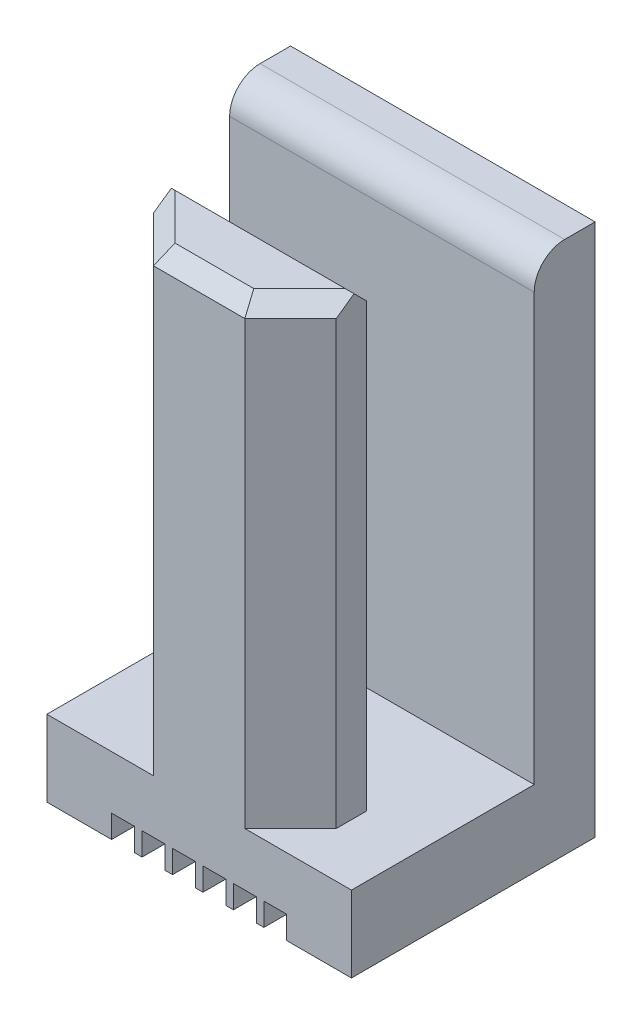
from build123d import *

# Parameters (mm, degrees)
SKETCH_1_W          = 20
SKETCH_1_H          = 16
EXTRUDE_1_DEPTH     = 5
SKETCH_2_W          = 20
SKETCH_2_H          = 4
EXTRUDE_2_DEPTH     = 30
CHAMFER_1_SIZE      = 1
FILLET_1_R          = 2
SKETCH_3_W          = 1.5
SKETCH_3_H          = 1.5
CUT_EXTRUDE_1_DEPTH = 17
SKETCH_5_W          = 2
SKETCH_5_H          = 2.998083063
SKETCH_5_H_2        = 3.102303799
CUT_EXTRUDE_2_DEPTH = 31


with BuildPart() as part:
    # 草图1 → 凸台-拉伸1 (new body)
    with BuildSketch(Plane(origin=(0, 0, 0), x_dir=(1, 0, 0), z_dir=(0, 1, 0))):
        with Locations((-1.867269937, -1.526468381)):
            Rectangle(SKETCH_1_W, SKETCH_1_H)
    extrude(amount=EXTRUDE_1_DEPTH)

    # 草图2 → 凸台-拉伸2 (add)
    with BuildSketch(Plane(origin=(0, 5, 0), x_dir=(1, 0, 0), z_dir=(0, 1, 0))):
        Polygon((-1.867269937, -9.526468381), (1.132730063, -9.526468381), (6.132730063, -4.526468381), (-1.867269937, -4.526468381), (-9.867269937, -4.526468381), (-4.867269937, -9.526468381), align=None)
        with Locations((-1.867269937, 4.473531619)):
            Rectangle(SKETCH_2_W, SKETCH_2_H)
    extrude(amount=EXTRUDE_2_DEPTH)

    # 倒角1
    chamfer_1_edges = [part.edges().sort_by_distance(p)[0] for p in [
        (-1.867269937, 35, 9.526468381),
        (3.632730063, 35, 7.026468381),
        (-1.867269937, 35, 4.526468381),
        (-7.367269937, 35, 7.026468381),
    ]]
    chamfer(chamfer_1_edges, length=CHAMFER_1_SIZE)

    # 圆角1
    fillet_1_edges = [part.edges().sort_by_distance(p)[0] for p in [
        (-1.867269937, 35, -2.473531619),
    ]]
    fillet(fillet_1_edges, radius=FILLET_1_R)

    # 草图3 → 切除-拉伸1 (cut, through all)
    with BuildSketch(Plane(origin=(0, 0, -6.473531619), x_dir=(-1, 0, 0), z_dir=(0, 0, -1))):
        with Locations((-3.132730063, 0.75)):
            Rectangle(SKETCH_3_W, SKETCH_3_H)
        with Locations((-1.132730063, 0.75)):
            Rectangle(SKETCH_3_W, SKETCH_3_H)
        with Locations((0.867269937, 0.75)):
            Rectangle(SKETCH_3_W, SKETCH_3_H)
        with Locations((2.867269937, 0.75)):
            Rectangle(SKETCH_3_W, SKETCH_3_H)
        with Locations((4.867269937, 0.75)):
            Rectangle(SKETCH_3_W, SKETCH_3_H)
        with Locations((6.867269937, 0.75)):
            Rectangle(SKETCH_3_W, SKETCH_3_H)
    extrude(amount=-CUT_EXTRUDE_1_DEPTH, mode=Mode.SUBTRACT)

    # 草图5 → 切除-拉伸2 (cut, through all)
    with BuildSketch(Plane(origin=(0, 5, 0), x_dir=(1, 0, 0), z_dir=(0, 1, 0))):
        with Locations((-8.867269937, -6.025509913)):
            Rectangle(SKETCH_5_W, SKETCH_5_H)
        with Locations((5.132730063, -6.07762028)):
            Rectangle(SKETCH_5_W, SKETCH_5_H_2)
    extrude(amount=CUT_EXTRUDE_2_DEPTH, mode=Mode.SUBTRACT)


solid = part.part
